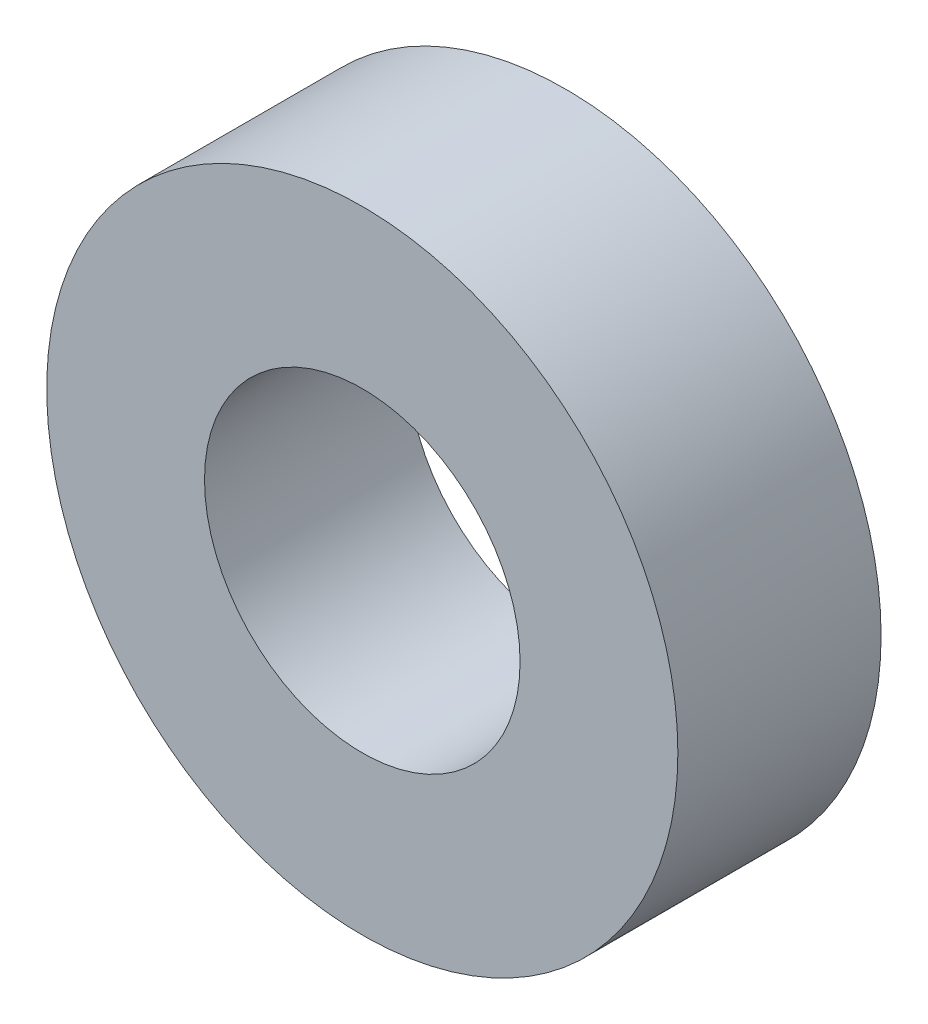
from build123d import *

# Parameters (mm, degrees)
SKETCH1_R           = 9.525
SKETCH1_R_2         = 4.7625
BOSS_EXTRUDE1_DEPTH = 6.13400094


with BuildPart() as part:
    # Sketch1 → Boss-Extrude1 (new body)
    with BuildSketch(Plane.XY):
        Circle(SKETCH1_R)
        Circle(SKETCH1_R_2, mode=Mode.SUBTRACT)
    extrude(amount=BOSS_EXTRUDE1_DEPTH)


solid = part.part
